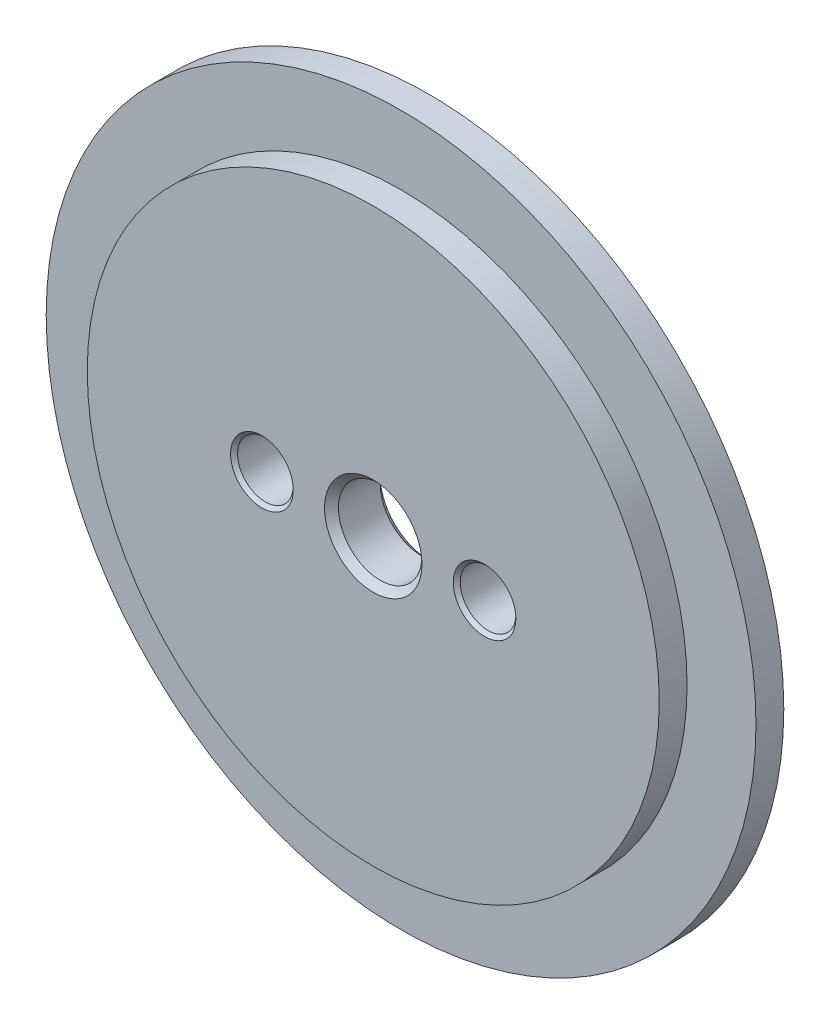
from build123d import *

# Parameters (mm, degrees)
SKETCH1_R           = 25.5
BOSS_EXTRUDE1_DEPTH = 2
SKETCH2_R           = 20.55
BOSS_EXTRUDE2_DEPTH = 2
SKETCH3_R           = 3
SKETCH3_R_2         = 2
CUT_EXTRUDE1_DEPTH  = 5
CHAMFER1_SIZE       = 0.25
CHAMFER2_SIZE       = 0.25
CHAMFER3_SIZE       = 0.5


with BuildPart() as part:
    # Sketch1 → Boss-Extrude1 (new body)
    with BuildSketch(Plane.XY):
        Circle(SKETCH1_R)
    extrude(amount=BOSS_EXTRUDE1_DEPTH)

    # Sketch2 → Boss-Extrude2 (add)
    with BuildSketch(Plane.XY.offset(2)):
        Circle(SKETCH2_R)
    extrude(amount=BOSS_EXTRUDE2_DEPTH)

    # Sketch3 → Cut-Extrude1 (cut, through all)
    with BuildSketch(Plane(origin=(0, 0, 0), x_dir=(-1, 0, 0), z_dir=(0, 0, -1))):
        Circle(SKETCH3_R)
        with Locations((8, 0)):
            Circle(SKETCH3_R_2)
        with Locations((-8, 0)):
            Circle(SKETCH3_R_2)
    extrude(amount=-CUT_EXTRUDE1_DEPTH, mode=Mode.SUBTRACT)

    # Chamfer1
    chamfer1_edges = [part.edges().sort_by_distance(p)[0] for p in [
        (10, 0, 4),
        (10, 0, 0),
    ]]
    chamfer(chamfer1_edges, length=CHAMFER1_SIZE)

    # Chamfer2
    chamfer2_edges = [part.edges().sort_by_distance(p)[0] for p in [
        (-6, 0, 4),
        (-6, 0, 0),
    ]]
    chamfer(chamfer2_edges, length=CHAMFER2_SIZE)

    # Chamfer3
    chamfer3_edges = [part.edges().sort_by_distance(p)[0] for p in [
        (3, 0, 4),
        (3, 0, 0),
    ]]
    chamfer(chamfer3_edges, length=CHAMFER3_SIZE)


solid = part.part
